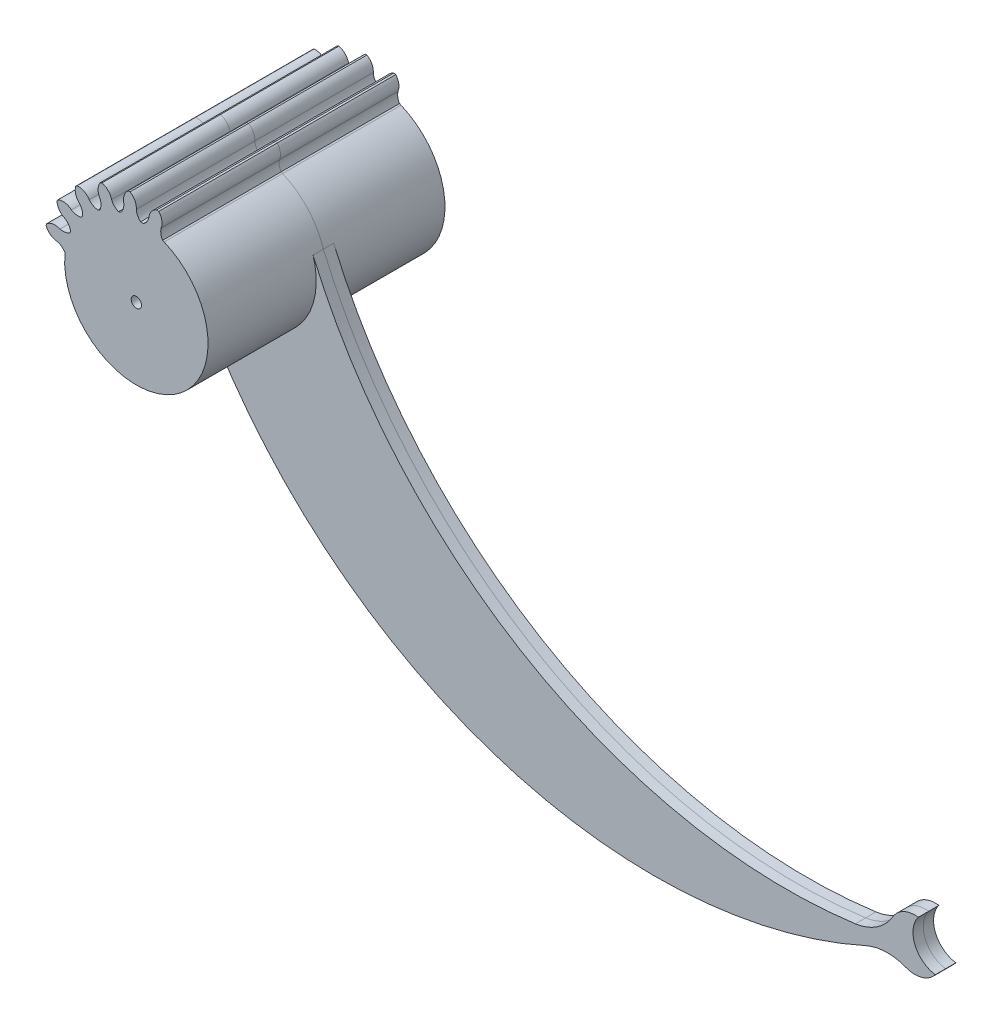
from build123d import *

# Parameters (mm, degrees)
ESQUISSE1_R             = 18
BOSS_EXTRU_1_DEPTH      = 23
ESQUISSE3_R             = 1
ENL_V_MAT_EXTRU_3_DEPTH = 35.307433597
BOSS_EXTRU_2_DEPTH      = 2
CONG_1_R                = 10
CONG_2_R                = 10


with BuildPart() as part:
    # Esquisse1 → Boss.-Extru.1 (new body)
    with BuildSketch(Plane.XY):
        Circle(ESQUISSE1_R)
    extrude(amount=-BOSS_EXTRU_1_DEPTH)

    # Esquisse3 → Enlèv. mat.-Extru.3 (cut, through all)
    with BuildSketch(Plane(origin=(0, 0, -23), x_dir=(-1, 0, 0), z_dir=(0, 0, -1))):
        with BuildLine():
            ThreePointArc((13.889472301, 0.971270565), (-7.29270091, -11.860747057), (-5.401914148, 12.832775649))
            Line((-5.401914148, 12.832775649), (-5.100509092, 12.969438951))
            ThreePointArc((-5.100509092, 12.969438951), (-4.765685498, 13.881250232), (-4.803657598, 14.851850443))
            ThreePointArc((-4.803657598, 14.851850443), (-4.957505402, 16.220683727), (-4.36298455, 17.463228963))
            ThreePointArc((-4.36298455, 17.463228963), (-9.368945013, -15.369543563), (17.521453605, 4.122943556))
            ThreePointArc((17.521453605, 4.122943556), (16.689385656, 3.025201949), (15.402187493, 2.534799463))
            ThreePointArc((15.402187493, 2.534799463), (14.540813003, 2.137466087), (13.889472301, 1.447832043))
            Line((13.889472301, 1.447832043), (13.889472301, 0.971270565))
        make_face()
        with BuildLine():
            ThreePointArc((11.000443663, 11.074422202), (10.524374819, 10.215627293), (10.415766238, 9.239730569))
            ThreePointArc((10.415766238, 9.239730569), (10.462012349, 9.18733394), (10.507994882, 9.134705846))
            Line((10.507994882, 9.134705846), (10.731094032, 8.911606695))
            ThreePointArc((10.731094032, 8.911606695), (11.691932834, 8.886448288), (12.591250594, 9.225670511))
            ThreePointArc((12.591250594, 9.225670511), (13.842476168, 9.801698523), (15.208877287, 9.627567278))
            ThreePointArc((15.208877287, 9.627567278), (13.644120592, 11.740441784), (11.788259754, 13.602828088))
            ThreePointArc((11.788259754, 13.602828088), (11.756646891, 12.225739007), (11.000443663, 11.074422202))
        make_face()
        with BuildLine():
            Line((12.765286048, 5.634000541), (12.874449055, 5.301826936))
            ThreePointArc((12.874449055, 5.301826936), (12.895585113, 5.250208748), (12.916514217, 5.198506303))
            ThreePointArc((12.916514217, 5.198506303), (13.838334104, 4.860248506), (14.81932063, 4.903093306))
            ThreePointArc((14.81932063, 4.903093306), (16.187092013, 5.066112175), (17.433594078, 4.479932758))
            ThreePointArc((17.433594078, 4.479932758), (16.594995048, 6.971810335), (15.402333491, 9.314940849))
            ThreePointArc((15.402333491, 9.314940849), (14.948466893, 8.014410642), (13.874653946, 7.151682723))
            ThreePointArc((13.874653946, 7.151682723), (13.171881983, 6.501088333), (12.765286048, 5.634000541))
        make_face()
        with BuildLine():
            ThreePointArc((-4.005414493, 17.548693819), (-2.913274427, 16.709287014), (-2.431510322, 15.418830872))
            ThreePointArc((-2.431510322, 15.418830872), (-2.060789897, 14.584674949), (-1.415325051, 13.939210103))
            Line((-1.415325051, 13.939210103), (-0.828029009, 13.939210103))
            ThreePointArc((-0.828029009, 13.939210103), (-0.252520041, 14.694227343), (0, 15.609375))
            ThreePointArc((0, 15.609375), (0.274865703, 16.959124071), (1.222917541, 17.958409526))
            ThreePointArc((1.222917541, 17.958409526), (-1.40625, 17.944984284), (-4.005414493, 17.548693819))
        make_face()
        with BuildLine():
            ThreePointArc((9.141071212, 12.652802258), (10.154306768, 13.585930018), (11.50798377, 13.840748157))
            ThreePointArc((11.50798377, 13.840748157), (9.368945013, 15.369543563), (7.030015125, 16.570422063))
            ThreePointArc((7.030015125, 16.570422063), (7.423724348, 15.250434656), (7.058528078, 13.922276009))
            ThreePointArc((7.058528078, 13.922276009), (6.869836592, 12.962423447), (7.063912165, 12.003645011))
            Line((7.063912165, 12.003645011), (7.465689298, 11.781332023))
            ThreePointArc((7.465689298, 11.781332023), (8.388832813, 12.052786521), (9.141071212, 12.652802258))
        make_face()
        with BuildLine():
            ThreePointArc((6.690123005, 16.710543204), (4.184417725, 17.506874316), (1.589435797, 17.9296875))
            ThreePointArc((1.589435797, 17.9296875), (2.37025361, 16.794920012), (2.431510322, 15.418830872))
            ThreePointArc((2.431510322, 15.418830872), (2.537604324, 14.478038859), (2.985925197, 13.644160005))
            Line((2.985925197, 13.644160005), (3.460890209, 13.499921317))
            ThreePointArc((3.460890209, 13.499921317), (4.266125885, 14.042940985), (4.803657598, 14.851850443))
            ThreePointArc((4.803657598, 14.851850443), (5.480558287, 16.051508379), (6.690123005, 16.710543204))
        make_face()
        Circle(ESQUISSE3_R)
    extrude(amount=-ENL_V_MAT_EXTRU_3_DEPTH, mode=Mode.SUBTRACT)


with BuildPart() as body_2:
    # Esquisse4 → Boss.-Extru.2 (new body)
    with BuildSketch(Plane(origin=(0, 0, -23), x_dir=(-1, 0, 0), z_dir=(0, 0, -1))):
        with BuildLine():
            ThreePointArc((12.644316935, -5.829413054), (-4.965169165, -13.007993792), (-13.312678081, 4.078407731))
            ThreePointArc((-13.312678081, 4.078407731), (-58.860226238, -45.189997217), (-125.296750737, -54.578451916))
            ThreePointArc((-125.296750737, -54.578451916), (-126.47076997, -50.089238619), (-130.829714456, -48.498339455))
            ThreePointArc((-130.829714456, -48.498339455), (-130.16877798, -53.454463241), (-134.130438845, -56.504912911))
            ThreePointArc((-134.130438845, -56.504912911), (-129.79196599, -58.440244295), (-125.793646659, -55.874840467))
            ThreePointArc((-125.793646659, -55.874840467), (-45.591937323, -61.233052926), (12.644316935, -5.829413054))
        make_face()
    extrude(amount=-BOSS_EXTRU_2_DEPTH)


with BuildPart() as body_3:
    # Symétrie1: mirrored copy
    add(part.part.mirror(Plane.XY.offset(-23)))


with BuildPart() as body_4:
    # Sym_trie1 2: mirrored copy
    add(body_2.part.mirror(Plane.XY.offset(-23)))

    # Congé2
    cong_2_edges = [body_4.edges().sort_by_distance(p)[0] for p in [
        (125.793646659, -55.874840467, -24),
        (125.296750737, -54.578451916, -24),
    ]]
    fillet(cong_2_edges, radius=CONG_2_R)


with BuildPart() as body_2_1:
    add(body_2.part)

    # Congé1
    cong_1_edges = [body_2_1.edges().sort_by_distance(p)[0] for p in [
        (125.793646659, -55.874840467, -22),
        (125.296750737, -54.578451916, -22),
    ]]
    fillet(cong_1_edges, radius=CONG_1_R)


solid = Compound([part.part, body_3.part, body_4.part, body_2_1.part])
